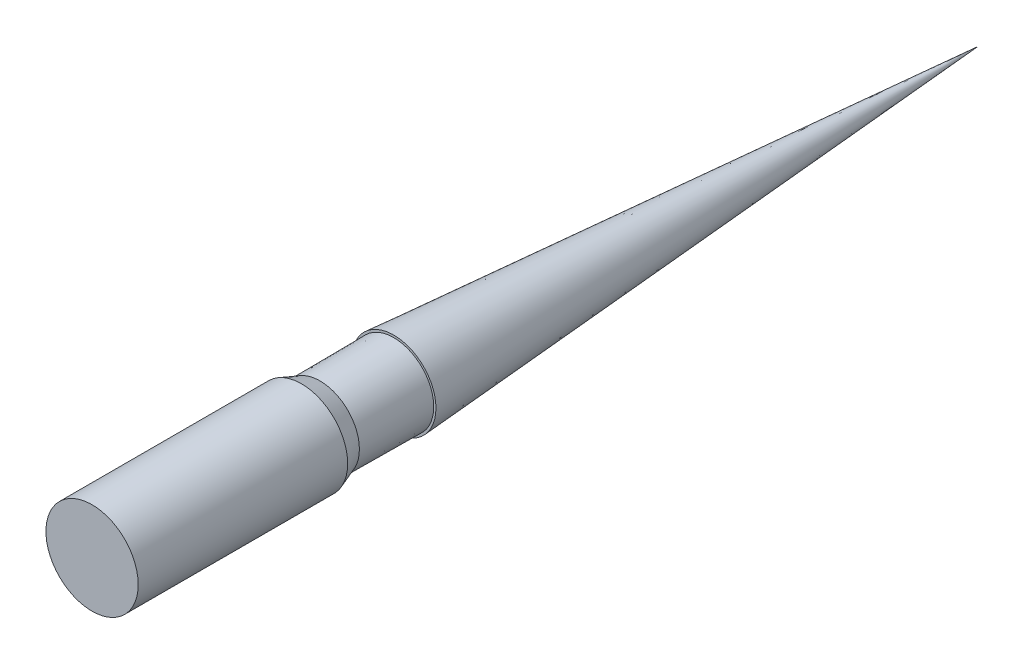
from build123d import *

# Parameters (mm, degrees)
SKETCH1_R           = 15.875
BOSS_EXTRUDE1_DEPTH = 304.8


with BuildPart() as part:
    # Sketch1 → Boss-Extrude1 (new body)
    with BuildSketch(Plane.XY):
        Circle(SKETCH1_R)
    extrude(amount=BOSS_EXTRUDE1_DEPTH)

    # Sketch2 → Cut-Revolve9 (revolve, cut)
    with BuildSketch(Plane(origin=(0, 0, 0), x_dir=(0, 0, -1), z_dir=(1, 0, 0))):
        Polygon((0, 0), (-200.9902, 14.5034), (-200.9902, 13.7414), (-226.3902, 13.5636), (-232.7402, 15.875), (-232.7402, 31.694033842), (2.194318367, 31.694033842), (0.985250692, 0), align=None)
    revolve(axis=Axis((0, 0, 371.81049345), (0, 0, -1)), mode=Mode.SUBTRACT)


solid = part.part
